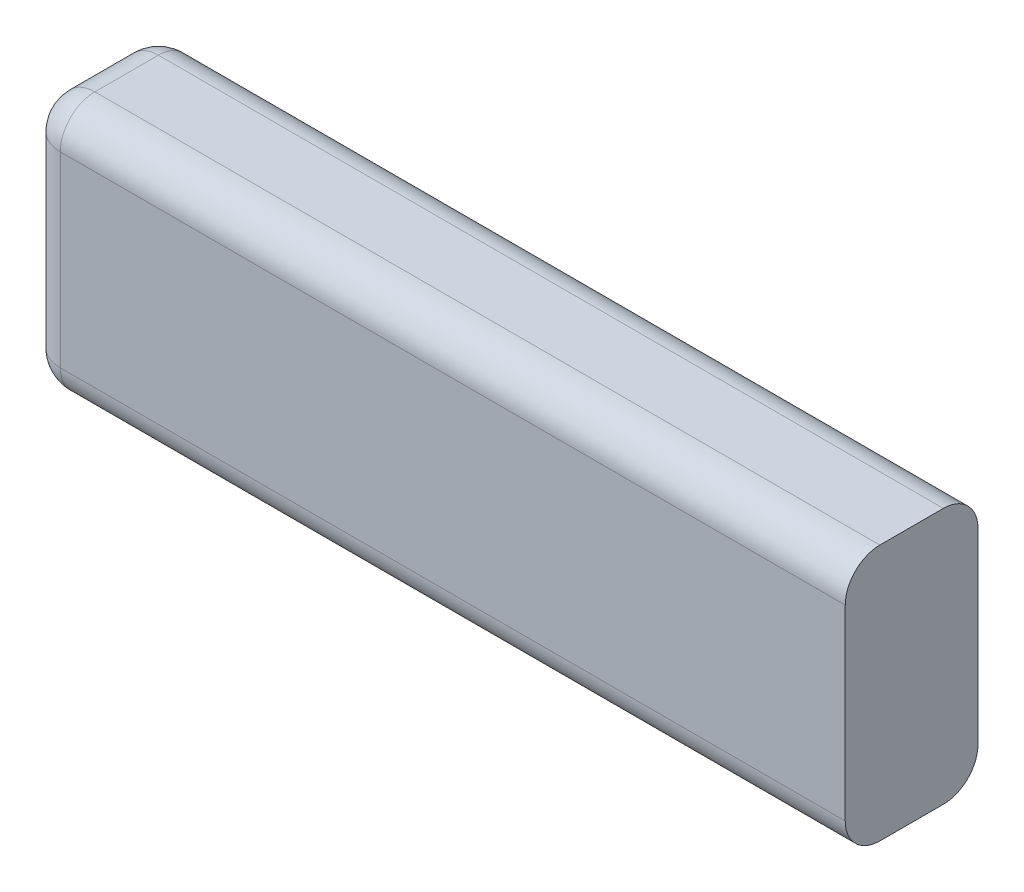
from build123d import *

# Parameters (mm, degrees)
SKETCH1_W           = 35.5
SKETCH1_H           = 11.1
BOSS_EXTRUDE1_DEPTH = 5.75
FILLET1_R           = 1.5


with BuildPart() as part:
    # Sketch1 → Boss-Extrude1 (new body)
    with BuildSketch(Plane.XY):
        with Locations((17.75, 5.55)):
            Rectangle(SKETCH1_W, SKETCH1_H)
    extrude(amount=BOSS_EXTRUDE1_DEPTH)

    # Fillet1
    fillet1_edges = [part.edges().sort_by_distance(p)[0] for p in [
        (17.75, 11.1, 5.75),
        (0, 5.55, 5.75),
        (17.75, 11.1, 0),
        (17.75, 0, 0),
        (0, 5.55, 0),
        (17.75, 0, 5.75),
        (0, 11.1, 2.875),
        (0, 0, 2.875),
    ]]
    fillet(fillet1_edges, radius=FILLET1_R)


solid = part.part
